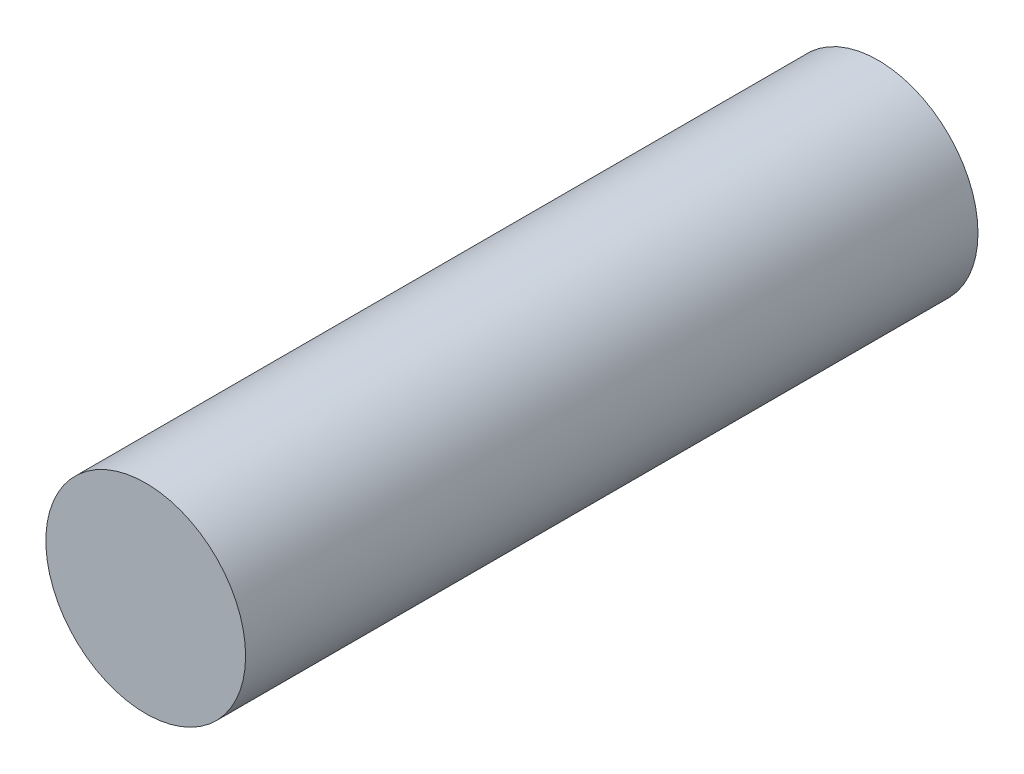
from build123d import *

# Parameters (mm, degrees)
SKETCH1_R           = 6
BOSS_EXTRUDE1_DEPTH = 44


with BuildPart() as part:
    # Sketch1 → Boss-Extrude1 (new body)
    with BuildSketch(Plane.XY):
        Circle(SKETCH1_R)
    extrude(amount=BOSS_EXTRUDE1_DEPTH)


solid = part.part
